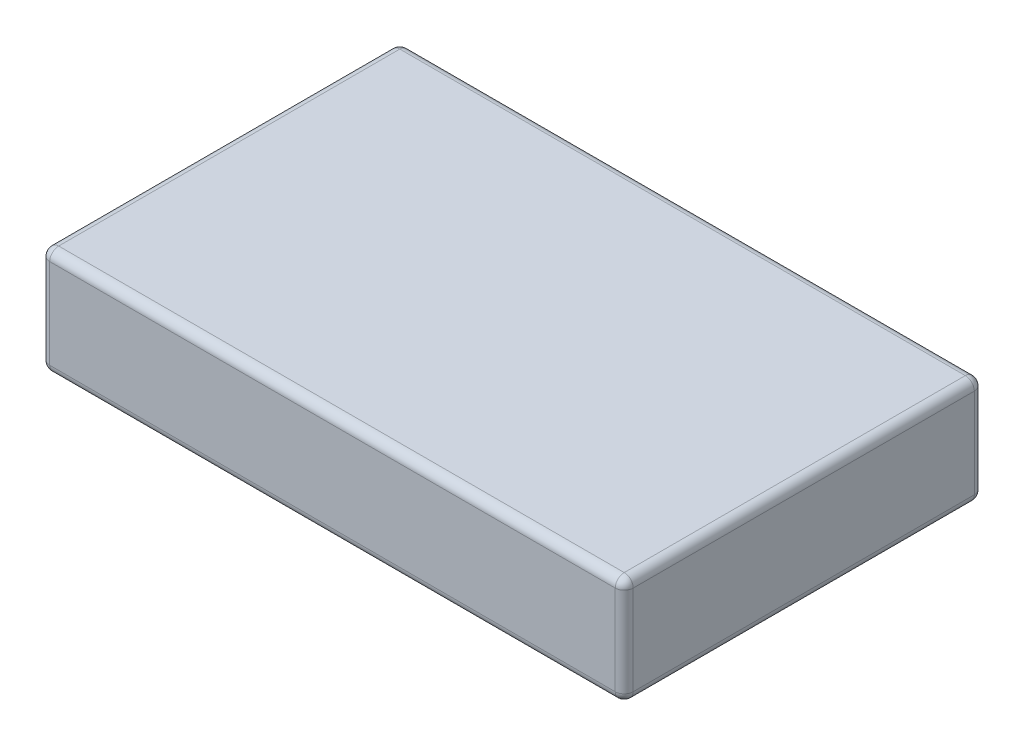
from build123d import *

# Parameters (mm, degrees)
SKETCH2_W           = 65
SKETCH2_H           = 40
BOSS_EXTRUDE1_DEPTH = 12
FILLET1_R           = 1


with BuildPart() as part:
    # Sketch2 → Boss-Extrude1 (new body)
    with BuildSketch(Plane(origin=(0, 0, 0), x_dir=(1, 0, 0), z_dir=(0, 1, 0))):
        with Locations((32.5, 20)):
            Rectangle(SKETCH2_W, SKETCH2_H)
    extrude(amount=BOSS_EXTRUDE1_DEPTH)

    # Fillet1
    fillet1_edges = [part.edges().sort_by_distance(p)[0] for p in [
        (65, 12, -20),
        (32.5, 12, -40),
        (0, 12, -20),
        (32.5, 0, -40),
        (65, 0, -20),
        (32.5, 0, 0),
        (0, 0, -20),
        (0, 6, -40),
        (65, 6, -40),
        (65, 6, 0),
        (0, 6, 0),
        (32.5, 12, 0),
    ]]
    fillet(fillet1_edges, radius=FILLET1_R)


solid = part.part
